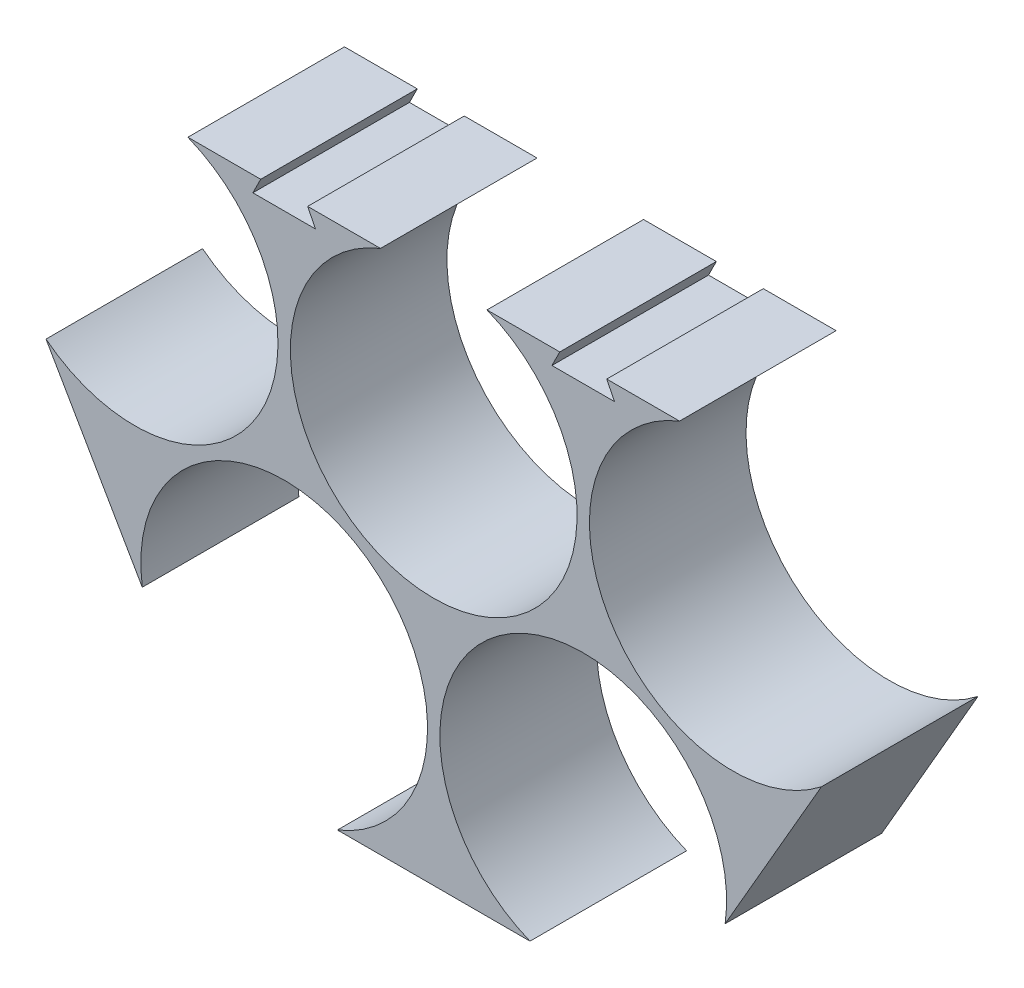
from build123d import *

# Parameters (mm, degrees)
BOSS_EXTRUDE1_DEPTH = 10
CUT_EXTRUDE1_DEPTH  = 11


with BuildPart() as part:
    # Sketch4 → Boss-Extrude1 (new body)
    with BuildSketch(Plane.XY):
        with BuildLine():
            Line((-47.308119418, -14.350263576), (-41.158711278, -25.001350911))
            ThreePointArc((-41.158711278, -25.001350911), (-27.519699416, -15.767887278), (-28.696607556, -32.196349849))
            Line((-28.696607556, -32.196349849), (-16.397791276, -32.196349849))
            ThreePointArc((-16.397791276, -32.196349849), (-17.574699416, -15.767887278), (-3.935687554, -25.001350911))
            Line((-3.935687554, -25.001350911), (2.213720586, -14.350263576))
            ThreePointArc((2.213720586, -14.350263576), (-11.375661988, -11.732764637), (-6.847791276, 1.344735363))
            Line((-6.847791276, 1.344735363), (-19.146607556, 1.344735363))
            ThreePointArc((-19.146607556, 1.344735363), (-22.547199416, -16.310264637), (-25.947791276, 1.344735363))
            Line((-25.947791276, 1.344735363), (-38.246607556, 1.344735363))
            ThreePointArc((-38.246607556, 1.344735363), (-33.718736844, -11.732764637), (-47.308119418, -14.350263576))
        make_face()
    extrude(amount=BOSS_EXTRUDE1_DEPTH)

    # Sketch5 → Cut-Extrude1 (cut, through all)
    with BuildSketch(Plane(origin=(0, 0, 0), x_dir=(-1, 0, 0), z_dir=(0, 0, -1))):
        Polygon((12.997199416, 1.344735363), (12.997199416, 0.344735363), (14.997199416, 0.344735363), (14.497199416, 1.344735363), align=None)
        Polygon((11.497199416, 1.344735363), (10.997199416, 0.344735363), (12.997199416, 0.344735363), (12.997199416, 1.344735363), align=None)
        Polygon((32.097199416, 0.344735363), (32.097199416, 1.344735363), (30.597199416, 1.344735363), (30.097199416, 0.344735363), align=None)
        Polygon((33.597199416, 1.344735363), (32.097199416, 1.344735363), (32.097199416, 0.344735363), (34.097199416, 0.344735363), align=None)
    extrude(amount=-CUT_EXTRUDE1_DEPTH, mode=Mode.SUBTRACT)


solid = part.part
